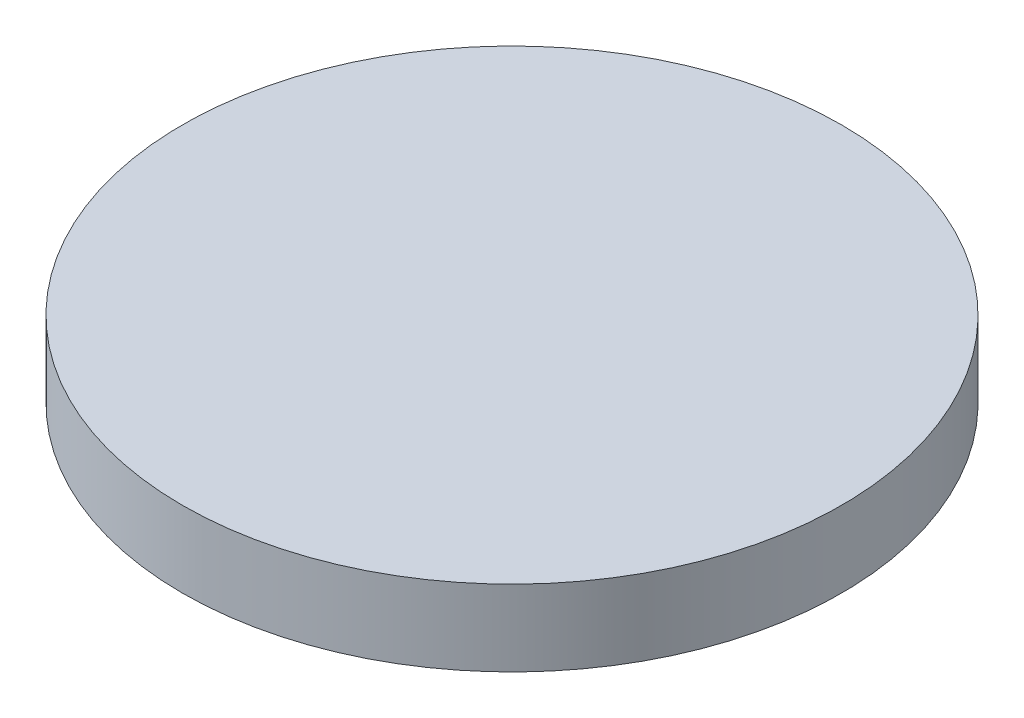
from build123d import *

# Parameters (mm, degrees)
SKETCH1_R           = 13
BOSS_EXTRUDE1_DEPTH = 3


with BuildPart() as part:
    # Sketch1 → Boss-Extrude1 (new body)
    with BuildSketch(Plane(origin=(0, 0, 0), x_dir=(1, 0, 0), z_dir=(0, 1, 0))):
        Circle(SKETCH1_R)
    extrude(amount=BOSS_EXTRUDE1_DEPTH)


solid = part.part
